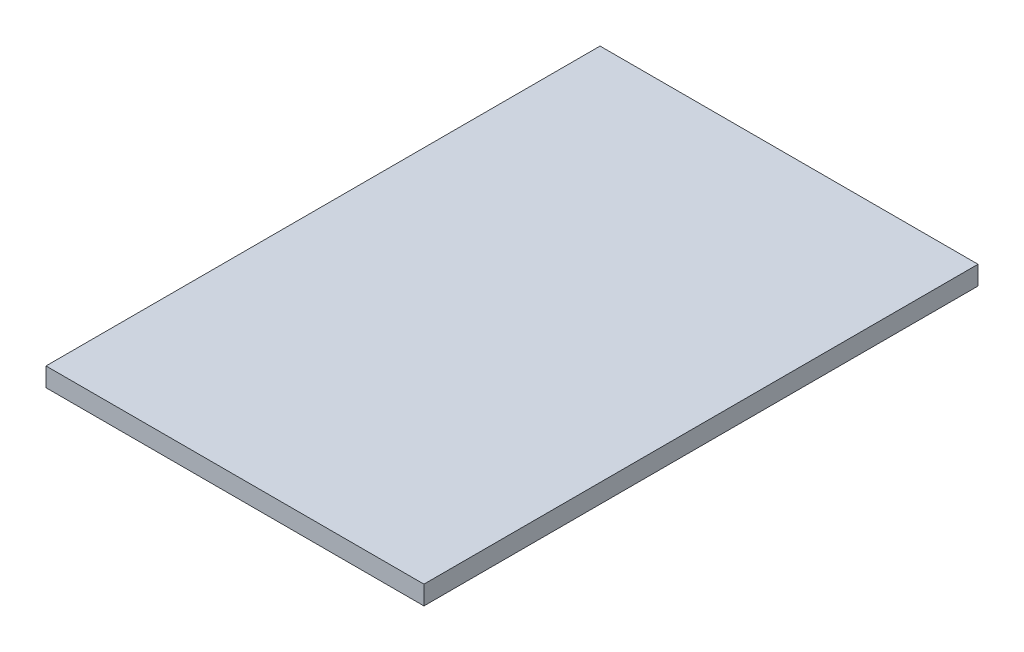
from build123d import *

# Parameters (mm, degrees)
SKETCH1_W           = 127
SKETCH1_H           = 186.182
BOSS_EXTRUDE1_DEPTH = 6.35


with BuildPart() as part:
    # Sketch1 → Boss-Extrude1 (new body)
    with BuildSketch(Plane(origin=(0, 0, 0), x_dir=(1, 0, 0), z_dir=(0, 1, 0))):
        Rectangle(SKETCH1_W, SKETCH1_H)
    extrude(amount=BOSS_EXTRUDE1_DEPTH)


solid = part.part
